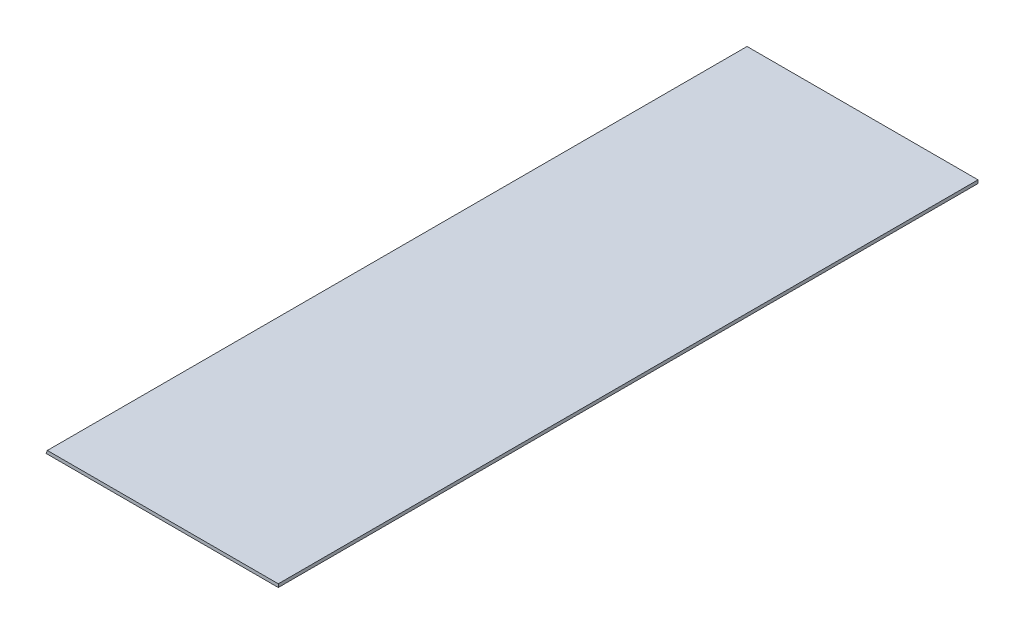
from build123d import *

# Parameters (mm, degrees)
BOSS_EXTRUDE1_DEPTH = 508


with BuildPart() as part:
    # Sketch1 → Boss-Extrude1 (new body)
    with BuildSketch(Plane.XY):
        Polygon((0, 0), (0.978455277, 2.3622), (168.656, 2.3622), (168.656, 0), align=None)
    extrude(amount=BOSS_EXTRUDE1_DEPTH)


solid = part.part
